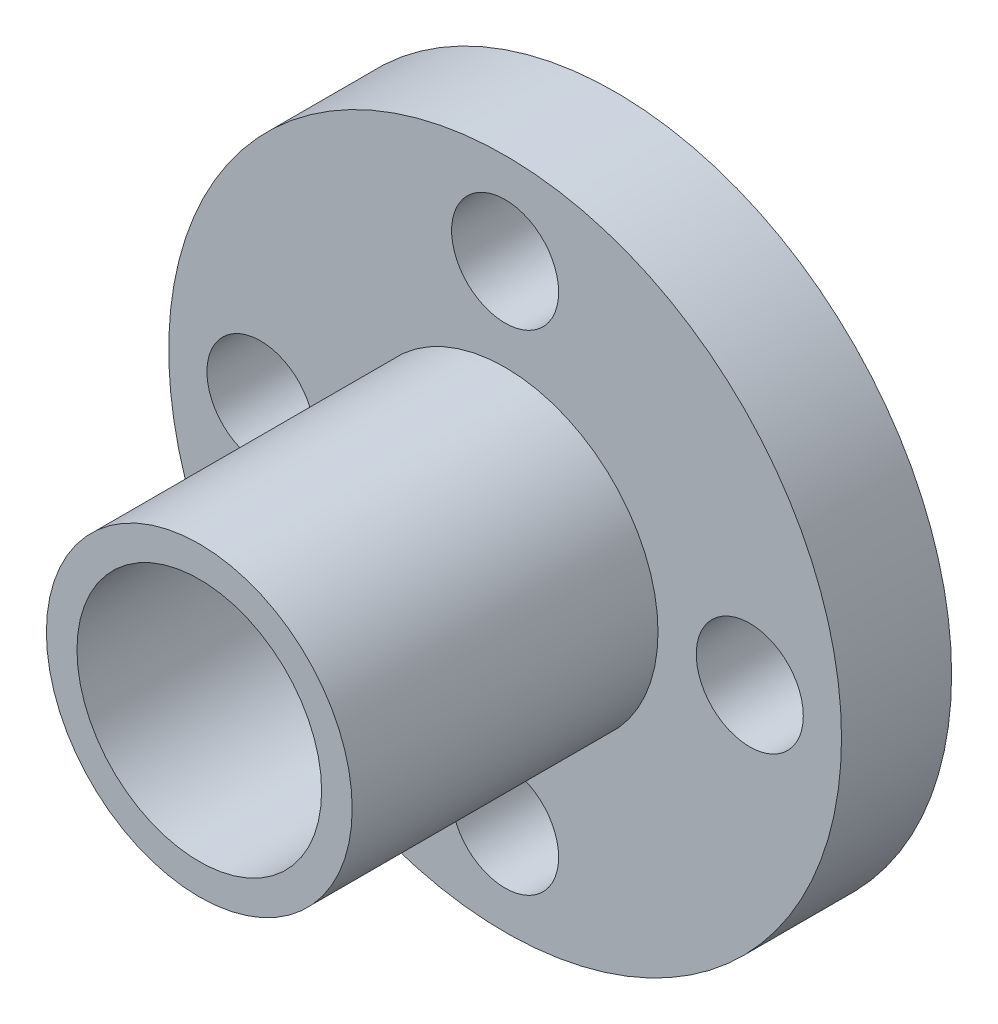
from build123d import *

# Parameters (mm, degrees)
SKETCH_1_R             = 11
SKETCH_1_R_2           = 1.75
EXTRUDE_1_DEPTH        = 3.6
SKETCH_2_R             = 5
SKETCH_2_R_2           = 4
EXTRUDE_1_2_DEPTH      = 10
EXTRUDE_1_2_DEPTH_BACK = 5.1
SKETCH_3_R             = 4
CUT_EXTRUDE_1_DEPTH    = 14.6


with BuildPart() as part:
    # Эскиз1 → Extrude 1 (new body)
    with BuildSketch(Plane.XY):
        Circle(SKETCH_1_R)
        with Locations((0, 8)):
            Circle(SKETCH_1_R_2, mode=Mode.SUBTRACT)
        with Locations((8, 0)):
            Circle(SKETCH_1_R_2, mode=Mode.SUBTRACT)
        with Locations((0, -8)):
            Circle(SKETCH_1_R_2, mode=Mode.SUBTRACT)
        with Locations((-8, 0)):
            Circle(SKETCH_1_R_2, mode=Mode.SUBTRACT)
    extrude(amount=EXTRUDE_1_DEPTH)

    # Эскиз2 → Extrude 1 2 (add, two sides)
    with BuildSketch(Plane.XY.offset(3.6)) as extrude_1_2_sk:
        Circle(SKETCH_2_R)
        Circle(SKETCH_2_R_2, mode=Mode.SUBTRACT)
    extrude(amount=EXTRUDE_1_2_DEPTH)
    extrude(extrude_1_2_sk.sketch, amount=-EXTRUDE_1_2_DEPTH_BACK)

    # Эскиз3 → Вырез-Вытянуть1 (cut, through all)
    with BuildSketch(Plane(origin=(0, 0, 0), x_dir=(-1, 0, 0), z_dir=(0, 0, -1))):
        Circle(SKETCH_3_R)
    extrude(amount=-CUT_EXTRUDE_1_DEPTH, mode=Mode.SUBTRACT)


solid = part.part
